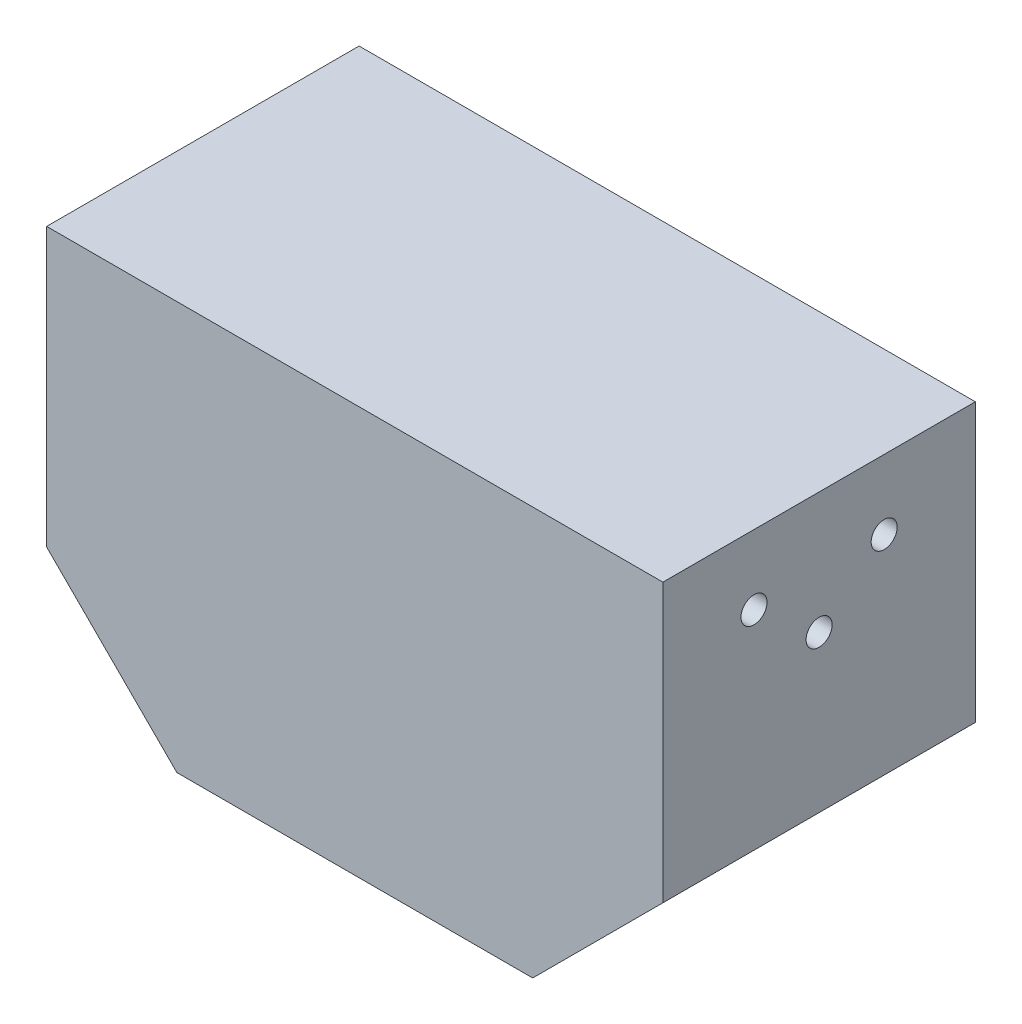
from build123d import *

# Parameters (mm, degrees)
SKETCH_1_W          = 71
SKETCH_1_H          = 36
EXTRUDE_1_DEPTH     = 47
CUT_EXTRUDE_1_DEPTH = 37
SKETCH_3_R          = 1.5
CUT_EXTRUDE_2_DEPTH = 20


with BuildPart() as part:
    # Эскиз1 → Бобышка-Вытянуть1 (new body)
    with BuildSketch(Plane(origin=(0, 0, 0), x_dir=(1, 0, 0), z_dir=(0, 1, 0))):
        Rectangle(SKETCH_1_W, SKETCH_1_H)
    extrude(amount=EXTRUDE_1_DEPTH)

    # Эскиз2 → Вырез-Вытянуть1 (cut, through all)
    with BuildSketch(Plane.XY.offset(18)):
        Polygon((-20.5, 0), (-35.5, 15), (-35.5, 0), align=None)
        Polygon((35.5, 15), (20.5, 0), (35.5, 0), align=None)
    extrude(amount=-CUT_EXTRUDE_1_DEPTH, mode=Mode.SUBTRACT)

    # Эскиз3 → Вырез-Вытянуть2 (cut)
    with BuildSketch(Plane(origin=(35.5, 0, 0), x_dir=(0, 0, -1), z_dir=(1, 0, 0))):
        with Locations((-7.5, 39)):
            Circle(SKETCH_3_R)
        with Locations((7.5, 39)):
            Circle(SKETCH_3_R)
        with Locations((0, 33)):
            Circle(SKETCH_3_R)
    cut_extrude_2 = extrude(amount=-CUT_EXTRUDE_2_DEPTH, mode=Mode.SUBTRACT)

    # Зеркальное отражение1: Вырез-Вытянуть2 across plane
    add(cut_extrude_2.mirror(Plane(origin=(0, 0, 0), x_dir=(0, 0, 1), z_dir=(1, 0, 0))), mode=Mode.SUBTRACT)


solid = part.part
